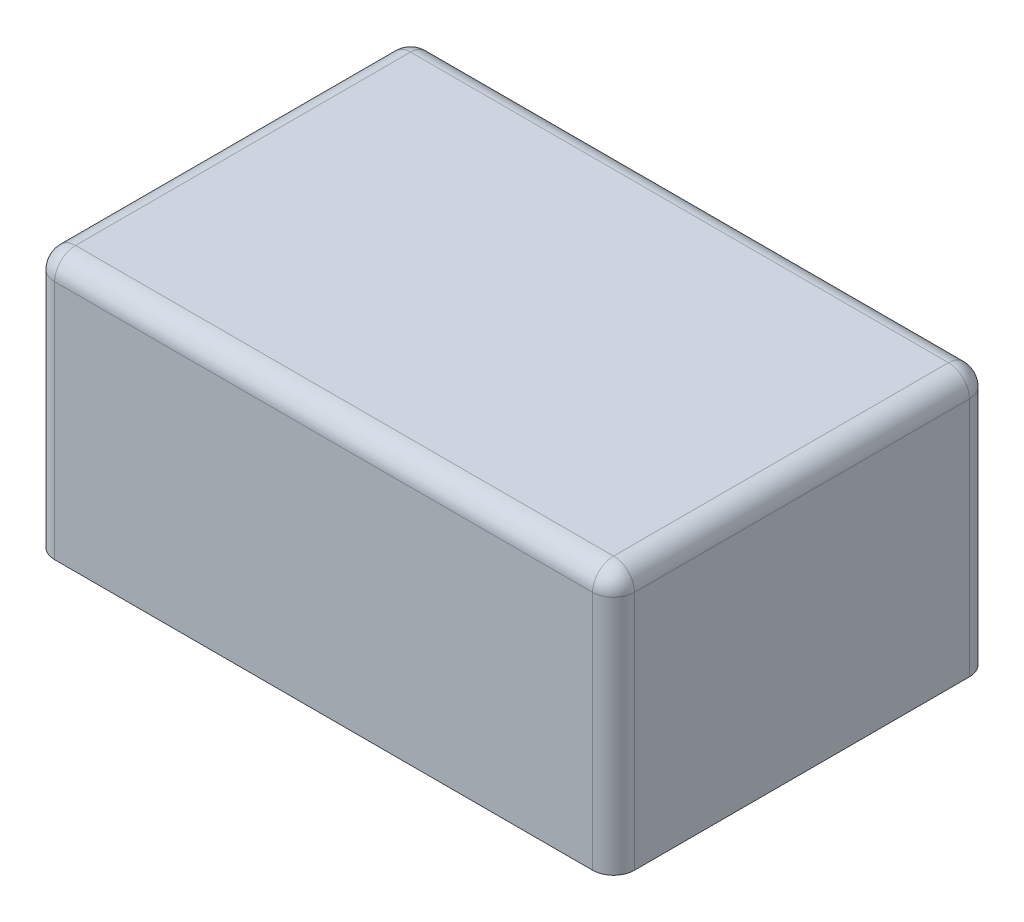
from build123d import *

# Parameters (mm, degrees)
SKETCH1_W           = 55.4
SKETCH1_H           = 36
BOSS_EXTRUDE1_DEPTH = 25
SKETCH2_R           = 0.5
BOSS_EXTRUDE2_DEPTH = 3
FILLET1_R           = 2


with BuildPart() as part:
    # Sketch1 → Boss-Extrude1 (new body)
    with BuildSketch(Plane(origin=(0, 0, 0), x_dir=(1, 0, 0), z_dir=(0, 1, 0))):
        Rectangle(SKETCH1_W, SKETCH1_H)
    extrude(amount=BOSS_EXTRUDE1_DEPTH)

    # Sketch2 → Boss-Extrude2 (add)
    with BuildSketch(Plane(origin=(0, 0, 0), x_dir=(1, 0, 0), z_dir=(0, 1, 0))):
        with Locations((-24, -6)):
            Circle(SKETCH2_R)
        with Locations((24, -6)):
            Circle(SKETCH2_R)
        with Locations((24, -1)):
            Circle(SKETCH2_R)
        with Locations((-24, 6)):
            Circle(SKETCH2_R)
    extrude(amount=-BOSS_EXTRUDE2_DEPTH)

    # Fillet1
    fillet1_edges = [part.edges().sort_by_distance(p)[0] for p in [
        (-27.7, 25, 0),
        (0, 25, 18),
        (27.7, 25, 0),
        (0, 25, -18),
        (27.7, 12.5, 18),
        (-27.7, 12.5, 18),
        (-27.7, 12.5, -18),
        (27.7, 12.5, -18),
    ]]
    fillet(fillet1_edges, radius=FILLET1_R)


solid = part.part
